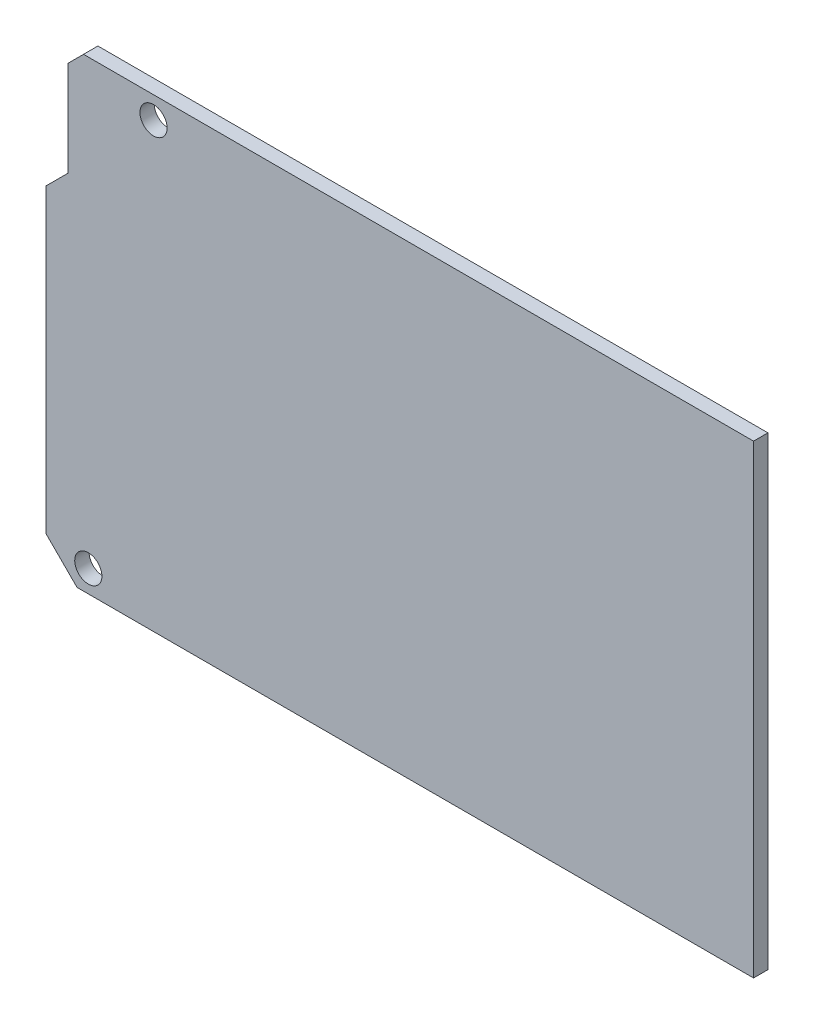
from build123d import *

# Parameters (mm, degrees)
SKETCH1_W               = 101.6
SKETCH1_H               = 53.4162
BOSS_EXTRUDE1_DEPTH     = 1.651
CHAMFER3_SIZE           = 3.556
CUT_EXTRUDE4_REACH      = 3.651
CUT_EXTRUDE5_REACH      = 3.651
SKETCH22_R              = 1.5621
ESQUISSE1_W             = 1.651
ESQUISSE1_H             = 53.4162
ENL_V_MAT_EXTRU_1_DEPTH = 20.32


with BuildPart() as part:
    # Sketch1 → Boss-Extrude1 (new body)
    with BuildSketch(Plane.XY):
        Rectangle(SKETCH1_W, SKETCH1_H)
    extrude(amount=BOSS_EXTRUDE1_DEPTH)

    # Chamfer3
    chamfer3_edges = [part.edges().sort_by_distance(p)[0] for p in [
        (-50.8, -26.7081, 0.8255),
    ]]
    chamfer(chamfer3_edges, length=CHAMFER3_SIZE)

    # Sketch13 → Cut-Extrude4 (cut, up to next)
    with BuildSketch(Plane(origin=(0, 0, 0), x_dir=(-1, 0, 0), z_dir=(0, 0, -1)), mode=Mode.PRIVATE) as cut_extrude4_sk1:
        Polygon((48.26, 24.9446647), (48.26, 14.0081), (50.8, 11.4681), (50.8, 26.7081), (46.4965647, 26.7081), align=None)
    cut_extrude4_tool1 = extrude(cut_extrude4_sk1.sketch, amount=-CUT_EXTRUDE4_REACH, mode=Mode.PRIVATE) & part.part
    add(cut_extrude4_tool1.solids().sort_by_distance((-49.48888, 19.973214, 0))[0], mode=Mode.SUBTRACT)

    # Sketch22 → Cut-Extrude5 (cut, up to next)
    with BuildSketch(Plane(origin=(0, 0, 0), x_dir=(-1, 0, 0), z_dir=(0, 0, -1)), mode=Mode.PRIVATE) as cut_extrude5_sk1:
        with Locations((38.4556, 24.1681)):
            Circle(SKETCH22_R)
    cut_extrude5_tool1 = extrude(cut_extrude5_sk1.sketch, amount=-CUT_EXTRUDE5_REACH, mode=Mode.PRIVATE) & part.part
    add(cut_extrude5_tool1.solids().sort_by_distance((-38.4556, 24.1681, 0))[0], mode=Mode.SUBTRACT)
    # Sketch22 → Cut-Extrude5 (cut, up to next)
    with BuildSketch(Plane(origin=(0, 0, 0), x_dir=(-1, 0, 0), z_dir=(0, 0, -1)), mode=Mode.PRIVATE) as cut_extrude5_sk2:
        with Locations((45.9486, -24.1681)):
            Circle(SKETCH22_R)
    cut_extrude5_tool2 = extrude(cut_extrude5_sk2.sketch, amount=-CUT_EXTRUDE5_REACH, mode=Mode.PRIVATE) & part.part
    add(cut_extrude5_tool2.solids().sort_by_distance((-45.9486, -24.1681, 0))[0], mode=Mode.SUBTRACT)

    # Esquisse1 → Enlèv. mat.-Extru.1 (cut)
    with BuildSketch(Plane(origin=(50.8, 0, 0), x_dir=(0, 0, -1), z_dir=(1, 0, 0))):
        with Locations((-0.8255, 0)):
            Rectangle(ESQUISSE1_W, ESQUISSE1_H)
    extrude(amount=-ENL_V_MAT_EXTRU_1_DEPTH, mode=Mode.SUBTRACT)


solid = part.part
